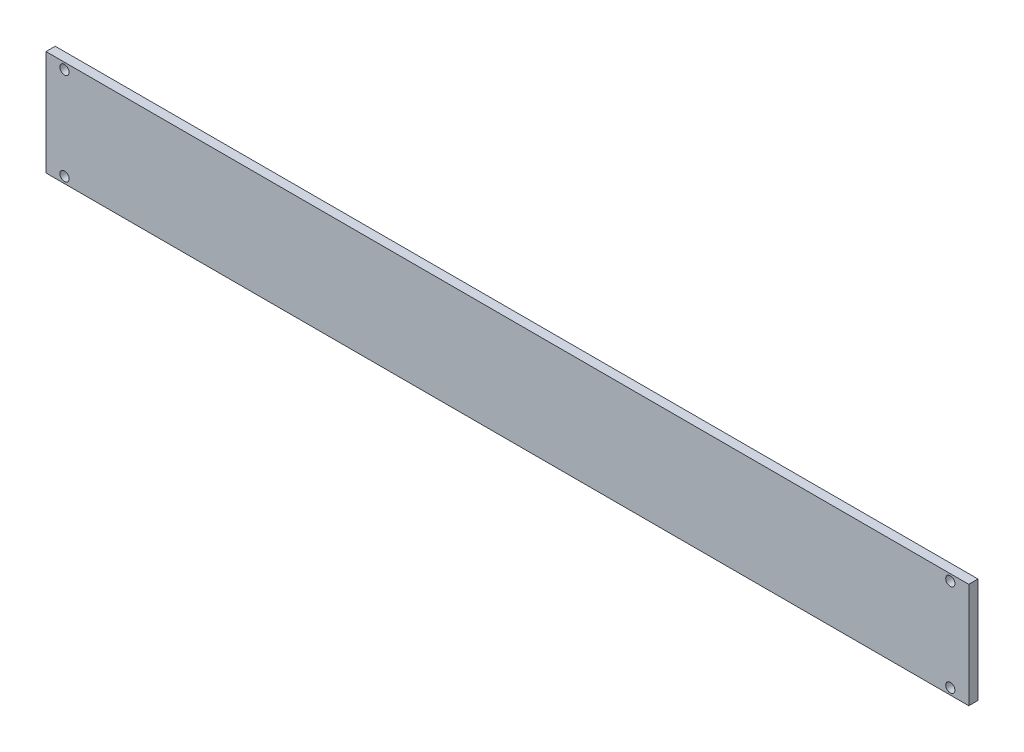
from build123d import *

# Parameters (mm, degrees)
SCHIZZO1_W                   = 1000
SCHIZZO1_H                   = 114
SCHIZZO1_R                   = 5
ESTRUSIONE_ESTRUSIONE1_DEPTH = 10


with BuildPart() as part:
    # Schizzo1 → Estrusione-Estrusione1 (new body)
    with BuildSketch(Plane.XY):
        Rectangle(SCHIZZO1_W, SCHIZZO1_H)
        with Locations((-480, 50)):
            Circle(SCHIZZO1_R, mode=Mode.SUBTRACT)
        with Locations((-480, -50)):
            Circle(SCHIZZO1_R, mode=Mode.SUBTRACT)
        with Locations((480, 50)):
            Circle(SCHIZZO1_R, mode=Mode.SUBTRACT)
        with Locations((480, -50)):
            Circle(SCHIZZO1_R, mode=Mode.SUBTRACT)
    extrude(amount=ESTRUSIONE_ESTRUSIONE1_DEPTH)


solid = part.part
